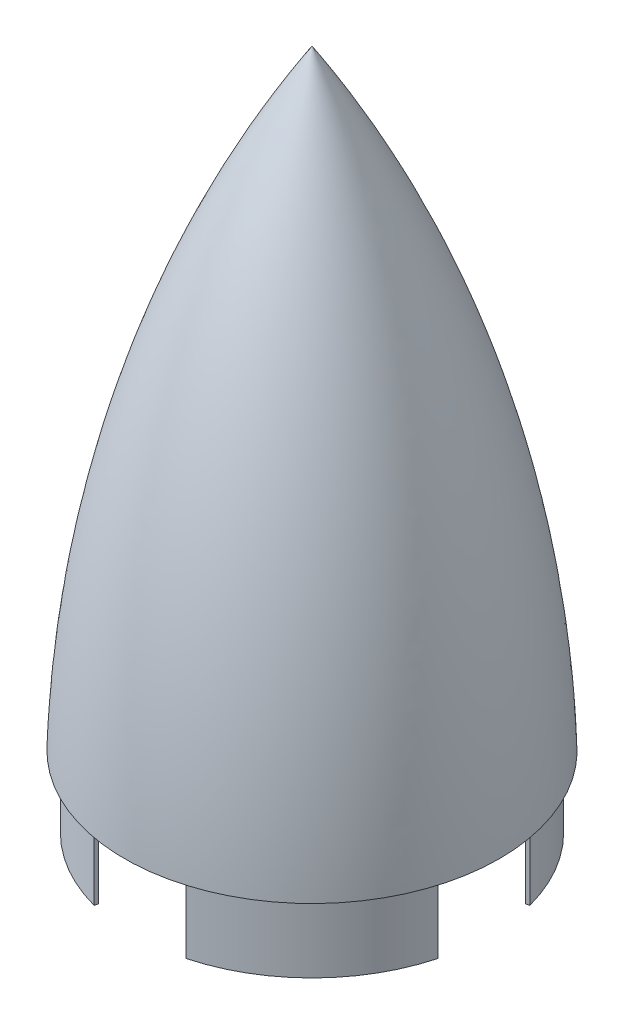
from build123d import *

# Parameters (mm, degrees)
SKETCH3_R           = 88.9
SKETCH3_R_2         = 86.995
BOSS_EXTRUDE1_DEPTH = 35.56
CUT_EXTRUDE1_DEPTH  = 35.56


with BuildPart() as part:
    # Sketch2 → Revolve1 (revolve)
    with BuildSketch(Plane.XY):
        with BuildLine():
            Line((-93.6498, 0), (-88.9, 0))
            ThreePointArc((-88.9, 0), (-62.950771459, 155.347516958), (0, 299.72))
            Line((0, 299.72), (0, 304.8))
            ThreePointArc((0, 304.8), (-67.390449504, 158.718765085), (-93.6498, 0))
        make_face()
    revolve(axis=Axis((0, 304.8, 0), (0, -1, 0)))


with BuildPart() as body_2:
    # Sketch3 → Boss-Extrude1 (new body)
    with BuildSketch(Plane.XZ):
        Circle(SKETCH3_R)
        Circle(SKETCH3_R_2, mode=Mode.SUBTRACT)
    extrude(amount=BOSS_EXTRUDE1_DEPTH)

    # Sketch4 → Cut-Extrude1 (cut)
    with BuildSketch(Plane.XZ):
        with BuildLine():
            Line((85.870805957, -23.00901311), (84.030717258, -22.515962829))
            ThreePointArc((84.030717258, -22.515962829), (86.995, 0), (84.030717258, 22.515962829))
            Line((84.030717258, 22.515962829), (85.870805957, 23.00901311))
            ThreePointArc((85.870805957, 23.00901311), (88.9, 0), (85.870805957, -23.00901311))
        make_face()
        with BuildLine():
            Line((-22.515962829, 84.030717258), (-23.00901311, 85.870805957))
            ThreePointArc((-23.00901311, 85.870805957), (0, 88.9), (23.00901311, 85.870805957))
            Line((23.00901311, 85.870805957), (22.515962829, 84.030717258))
            ThreePointArc((22.515962829, 84.030717258), (0, 86.995), (-22.515962829, 84.030717258))
        make_face()
        with BuildLine():
            Line((-84.030717258, -22.515962829), (-85.870805957, -23.00901311))
            ThreePointArc((-85.870805957, -23.00901311), (-88.9, 0), (-85.870805957, 23.00901311))
            Line((-85.870805957, 23.00901311), (-84.030717258, 22.515962829))
            ThreePointArc((-84.030717258, 22.515962829), (-86.995, 0), (-84.030717258, -22.515962829))
        make_face()
        with BuildLine():
            Line((23.00901311, -85.870805957), (22.515962829, -84.030717258))
            ThreePointArc((22.515962829, -84.030717258), (0, -86.995), (-22.515962829, -84.030717258))
            Line((-22.515962829, -84.030717258), (-23.00901311, -85.870805957))
            ThreePointArc((-23.00901311, -85.870805957), (0, -88.9), (23.00901311, -85.870805957))
        make_face()
    extrude(amount=CUT_EXTRUDE1_DEPTH, mode=Mode.SUBTRACT)


solid = Compound([part.part, body_2.part])
